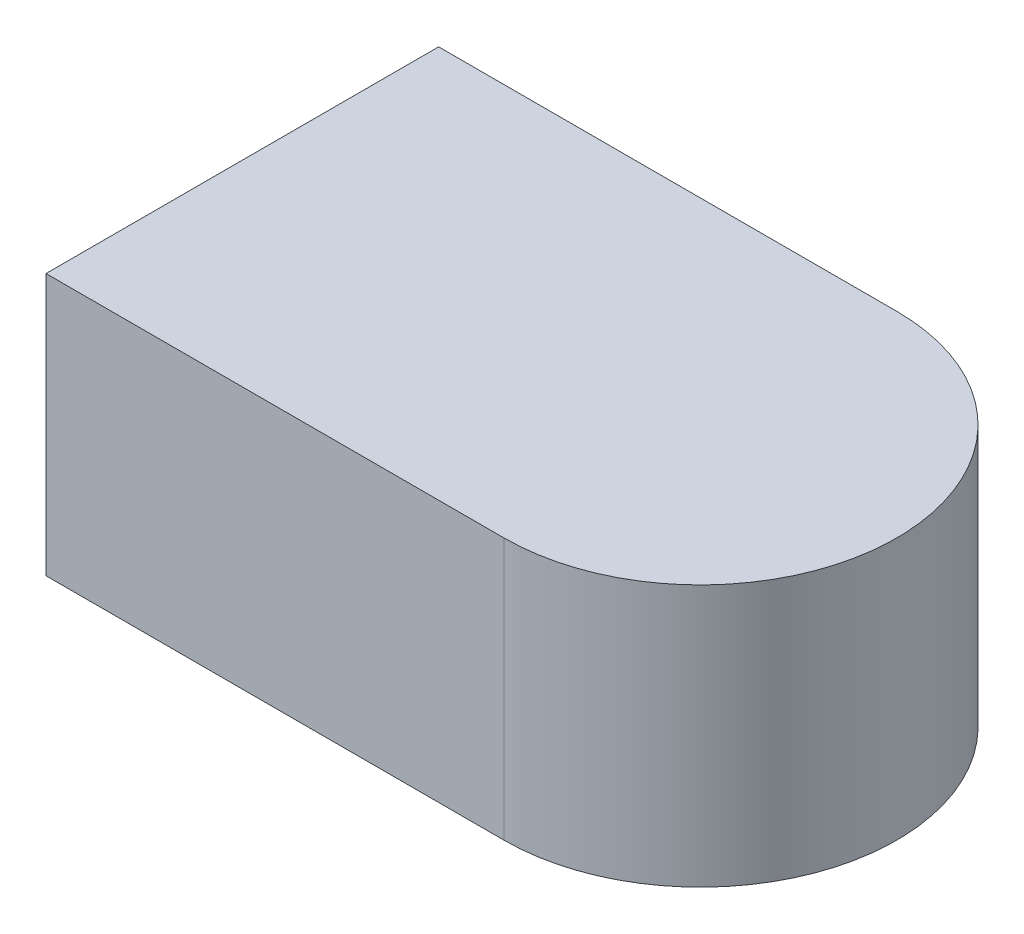
from build123d import *

# Parameters (mm, degrees)
BOSS_EXTRUDE1_DEPTH = 0.2


with BuildPart() as part:
    # Sketch1 → Boss-Extrude1 (new body)
    with BuildSketch(Plane(origin=(0, 0, 0), x_dir=(1, 0, 0), z_dir=(0, 1, 0))):
        with BuildLine():
            Line((-0.175, -0.15), (0.175, -0.15))
            ThreePointArc((0.175, -0.15), (0.325, 0), (0.175, 0.15))
            Line((0.175, 0.15), (-0.175, 0.15))
            Line((-0.175, 0.15), (-0.175, -0.15))
        make_face()
    extrude(amount=BOSS_EXTRUDE1_DEPTH)


solid = part.part
